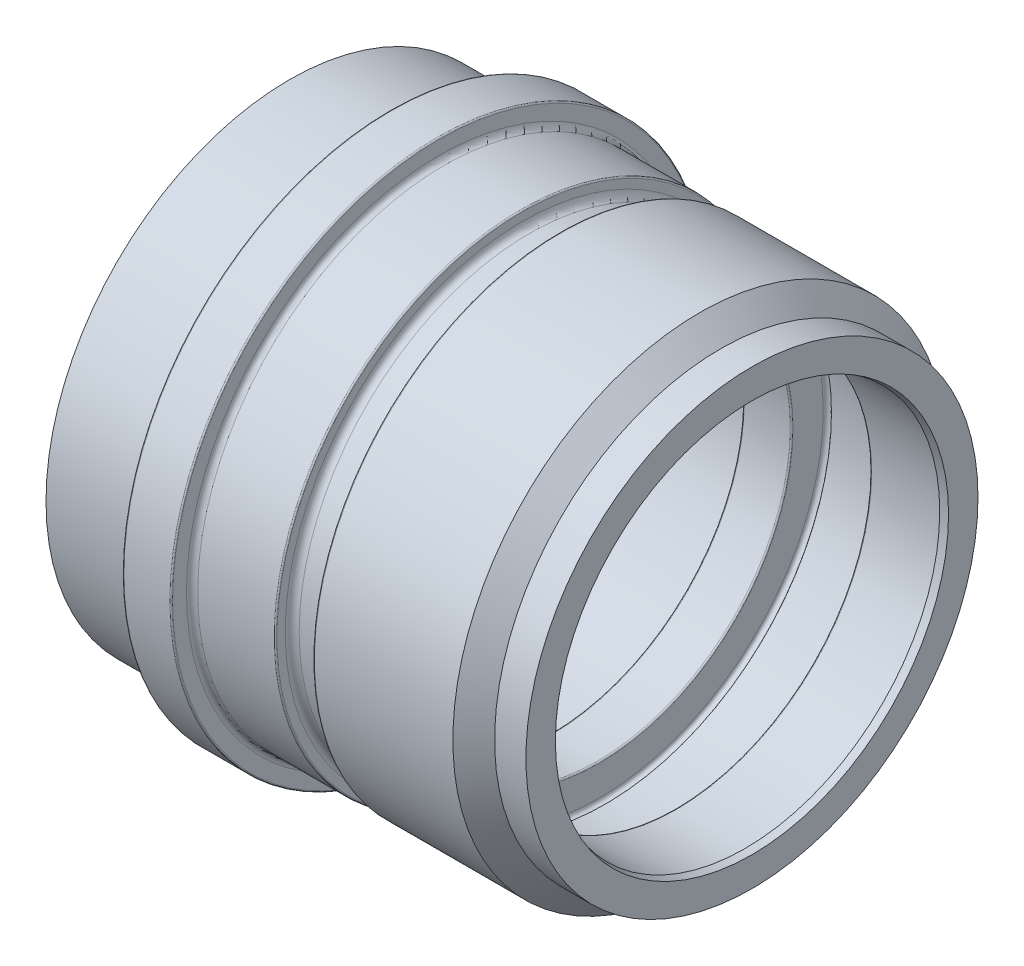
from build123d import *


with BuildPart() as part:
    # Sketch1 → Base-Revolve (revolve)
    with BuildSketch(Plane.XY):
        with BuildLine():
            Line((0, 36.3), (0, 38.3))
            ThreePointArc((0, 38.3), (-0.058578644, 38.441421356), (-0.2, 38.5))
            Line((-0.2, 38.5), (-6.8, 38.5))
            ThreePointArc((-6.8, 38.5), (-6.941421356, 38.441421356), (-7, 38.3))
            Line((-7, 38.3), (-7, 35.2))
            ThreePointArc((-7, 35.2), (-7.058578644, 35.058578644), (-7.2, 35))
            Line((-7.2, 35), (-21.5, 35))
            Line((-21.5, 35), (-21.5, 33.077350269))
            Line((-21.5, 33.077350269), (-20.5, 32.5))
            Line((-20.5, 32.5), (-14.8, 32.5))
            ThreePointArc((-14.8, 32.5), (-14.234314575, 32.265685425), (-14, 31.7))
            Line((-14, 31.7), (-14, 28))
            Line((-14, 28), (-9.2, 28))
            ThreePointArc((-9.2, 28), (-9.058578644, 28.058578644), (-9, 28.2))
            Line((-9, 28.2), (-9, 29.8))
            ThreePointArc((-9, 29.8), (-8.941421356, 29.941421356), (-8.8, 30))
            Line((-8.8, 30), (15.8, 30))
            ThreePointArc((15.8, 30), (15.941421356, 29.941421356), (16, 29.8))
            Line((16, 29.8), (16, 27.9))
            ThreePointArc((16, 27.9), (16.058578644, 27.758578644), (16.2, 27.7))
            Line((16.2, 27.7), (22.8, 27.7))
            ThreePointArc((22.8, 27.7), (22.941421356, 27.758578644), (23, 27.9))
            Line((23, 27.9), (23, 32.25))
            ThreePointArc((23, 32.25), (23.370590477, 32.732962913), (23.933012702, 32.5))
            Line((23.933012702, 32.5), (33.6, 32.5))
            ThreePointArc((33.6, 32.5), (33.882842712, 32.382842712), (34, 32.1))
            Line((34, 32.1), (34, 28.2))
            ThreePointArc((34, 28.2), (34.058578644, 28.058578644), (34.2, 28))
            Line((34.2, 28), (44, 28))
            Line((44, 28), (45, 28.267949192))
            Line((45, 28.267949192), (45, 32.5))
            Line((45, 32.5), (40.5, 32.5))
            Line((40.5, 32.5), (37.5, 35.5))
            Line((37.5, 35.5), (17.6, 35.5))
            ThreePointArc((17.6, 35.5), (17.458578644, 35.441421356), (17.4, 35.3))
            Line((17.4, 35.3), (17.4, 34.1))
            ThreePointArc((17.4, 34.1), (17.107106781, 33.392893219), (16.4, 33.1))
            Line((16.4, 33.1), (13, 33.1))
            ThreePointArc((13, 33.1), (12.292893219, 33.392893219), (12, 34.1))
            Line((12, 34.1), (12, 35.3))
            ThreePointArc((12, 35.3), (11.941421356, 35.441421356), (11.8, 35.5))
            Line((11.8, 35.5), (0.8, 35.5))
            ThreePointArc((0.8, 35.5), (0.234314575, 35.734314575), (0, 36.3))
        make_face()
    revolve(axis=Axis((0, 0, 0), (-1, 0, 0)))


solid = part.part
